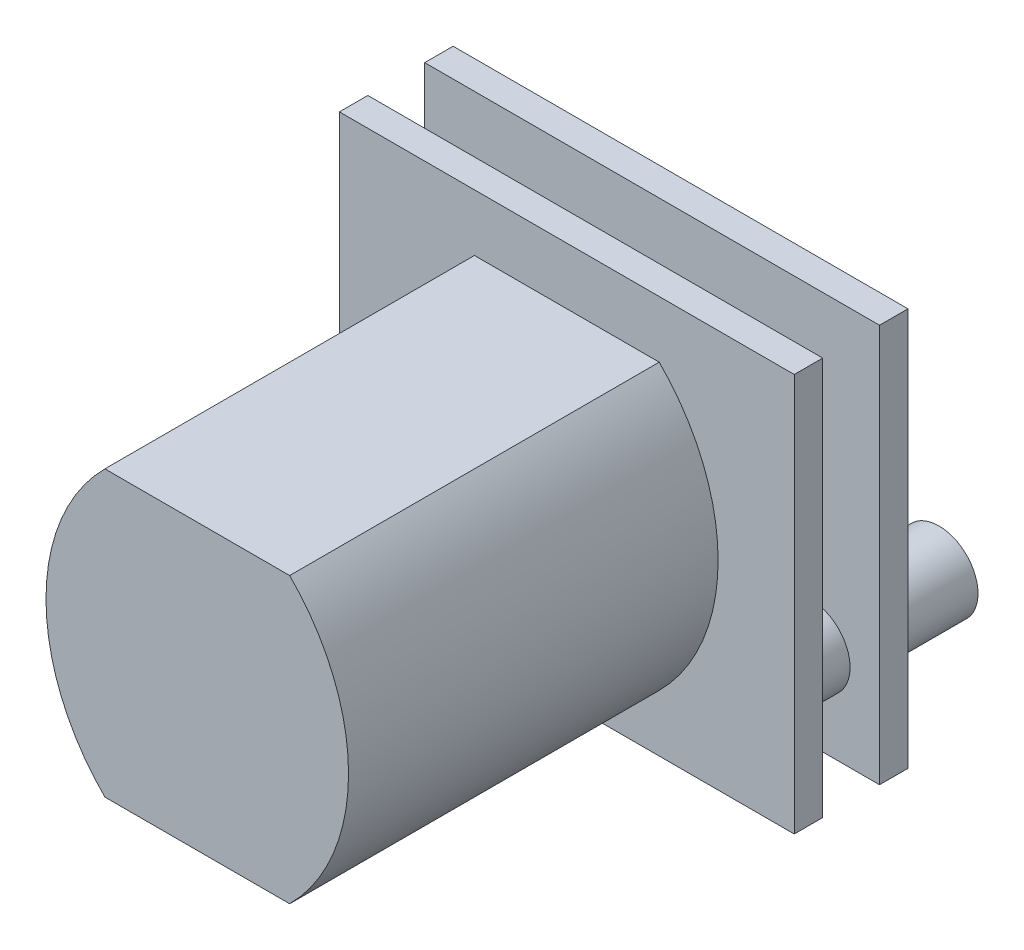
from build123d import *

# Parameters (mm, degrees)
EXTRUDE1_DEPTH  = 13
SKETCH2_W       = 16
SKETCH2_H       = 14
EXTRUDE2_DEPTH  = 1
SKETCH3_R       = 2.248676076
EXTRUDE3_DEPTH  = 1.2
SKETCH4_W       = 0.4
SKETCH4_H       = 0.5
EXTRUDE4_DEPTH  = 1.2
SKETCH5_R       = 1.372998475
EXTRUDE5_DEPTH  = 2
SKETCH6_W       = 16
SKETCH6_H       = 14
EXTRUDE6_DEPTH  = 1
SKETCH7_R       = 1.372998475
EXTRUDE7_DEPTH  = 3.5
SKETCH8_R       = 1.733936405
EXTRUDE8_DEPTH  = 1.2
SKETCH9_W       = 0.301521113
SKETCH9_H       = 0.224907716
EXTRUDE9_DEPTH  = 1.2
SKETCH10_W      = 0.800661527
SKETCH10_H      = 6.121277762
EXTRUDE10_DEPTH = 1.2
SKETCH11_R      = 0.601090718
EXTRUDE11_DEPTH = 1.2
SKETCH12_W      = 0.183794405
SKETCH12_H      = 0.118202218
EXTRUDE12_DEPTH = 1.2
SKETCH13_R      = 2.161420289
EXTRUDE13_DEPTH = 1.2
SKETCH14_W      = 0.467705932
SKETCH14_H      = 0.202573078
EXTRUDE14_DEPTH = 1.2
SKETCH15_R      = 0.577311245
EXTRUDE15_DEPTH = 1.4
SKETCH16_R      = 2.177574352
EXTRUDE16_DEPTH = 0.8
SKETCH17_W      = 0.286885117
SKETCH17_H      = 0.397850676
SKETCH17_W_2    = 0.397850676
SKETCH17_H_2    = 0.286885116
SKETCH17_W_3    = 0.397850677
SKETCH17_W_4    = 0.359139645
SKETCH17_H_3    = 0.201650404
EXTRUDE18_DEPTH = 0.8


with BuildPart() as part:
    # Sketch1 → Extrude1 (new body)
    with BuildSketch(Plane.XY):
        with BuildLine():
            Line((-3.25, 5), (3.25, 5))
            ThreePointArc((3.25, 5), (5.321067812, 0), (3.25, -5))
            Line((3.25, -5), (-3.25, -5))
            ThreePointArc((-3.25, -5), (-5.321067812, 0), (-3.25, 5))
        make_face()
    extrude(amount=EXTRUDE1_DEPTH)

    # Sketch2 → Extrude2 (add)
    with BuildSketch(Plane(origin=(0, 0, 0), x_dir=(-1, 0, 0), z_dir=(0, 0, -1))):
        Rectangle(SKETCH2_W, SKETCH2_H)
    extrude(amount=EXTRUDE2_DEPTH)

    # Sketch3 → Extrude3 (add)
    with BuildSketch(Plane(origin=(0, 0, -1), x_dir=(-1, 0, 0), z_dir=(0, 0, -1))):
        Circle(SKETCH3_R)
    extrude(amount=EXTRUDE3_DEPTH)

    # Sketch4 → Extrude4 (cut)
    with BuildSketch(Plane(origin=(0, 0, -2.2), x_dir=(-1, 0, 0), z_dir=(0, 0, -1))):
        Polygon((-0.459805613, -1.955322187), (-0.622155347, -2.428230808), (-1.000482244, -2.29835102), (-0.838132509, -1.825442399), align=None)
        with Locations((0, -2.248676076)):
            Rectangle(SKETCH4_W, SKETCH4_H)
        Polygon((-1.069784152, -1.700078799), (-1.376890509, -2.094649054), (-1.692546713, -1.848963969), (-1.385440356, -1.454393714), align=None)
        Polygon((-1.56383498, -1.260605494), (-1.982418219, -1.534079573), (-2.201197482, -1.199212982), (-1.782614243, -0.925738903), align=None)
        Polygon((-1.888420022, -0.684526023), (-2.373120155, -0.807268767), (-2.47131435, -0.41950866), (-1.986614217, -0.296765917), align=None)
        Polygon((-2.008365453, -0.034267536), (-2.506657699, 0.007022136), (-2.473625961, 0.405655933), (-1.975333715, 0.364366261), align=None)
        Polygon((-1.910673324, 0.61970437), (-2.368559987, 0.820552082), (-2.207881817, 1.186861413), (-1.749995154, 0.9860137), align=None)
        Polygon((-1.605930093, 1.206521692), (-1.973792048, 1.545162477), (-1.70287942, 1.839452042), (-1.335017464, 1.500811256), align=None)
        Polygon((-1.127159418, 1.662593667), (-1.365133115, 2.102330543), (-1.013343614, 2.2927095), (-0.775369918, 1.852972624), align=None)
        Polygon((-0.52624353, 1.938497821), (-0.608540826, 2.431678473), (-0.213996304, 2.497516309), (-0.131699009, 2.004335657), align=None)
        Polygon((0.131699009, 2.004335657), (0.213996304, 2.497516309), (0.608540826, 2.431678473), (0.52624353, 1.938497821), align=None)
        Polygon((0.775369918, 1.852972624), (1.013343614, 2.2927095), (1.365133115, 2.102330543), (1.127159418, 1.662593667), align=None)
        Polygon((1.335017464, 1.500811256), (1.70287942, 1.839452042), (1.973792048, 1.545162477), (1.605930093, 1.206521692), align=None)
        Polygon((1.749995154, 0.9860137), (2.207881817, 1.186861413), (2.368559987, 0.820552082), (1.910673324, 0.61970437), align=None)
        Polygon((1.975333715, 0.364366261), (2.473625961, 0.405655933), (2.506657699, 0.007022136), (2.008365453, -0.034267536), align=None)
        Polygon((1.986614217, -0.296765917), (2.47131435, -0.41950866), (2.373120155, -0.807268767), (1.888420022, -0.684526023), align=None)
        Polygon((1.782614243, -0.925738903), (2.201197482, -1.199212982), (1.982418219, -1.534079573), (1.56383498, -1.260605494), align=None)
        Polygon((1.385440356, -1.454393714), (1.692546713, -1.848963969), (1.376890509, -2.094649054), (1.069784152, -1.700078799), align=None)
        Polygon((0.838132509, -1.825442399), (1.000482244, -2.29835102), (0.622155347, -2.428230808), (0.459805613, -1.955322187), align=None)
    extrude(amount=-EXTRUDE4_DEPTH, mode=Mode.SUBTRACT)

    # Sketch5 → Extrude5 (add)
    with BuildSketch(Plane(origin=(0, 0, -1), x_dir=(-1, 0, 0), z_dir=(0, 0, -1))):
        with Locations((-5.590617774, -3.94150511)):
            Circle(SKETCH5_R)
    extrude(amount=EXTRUDE5_DEPTH)

    # Sketch6 → Extrude6 (add)
    with BuildSketch(Plane(origin=(0, 0, -3), x_dir=(-1, 0, 0), z_dir=(0, 0, -1))):
        Rectangle(SKETCH6_W, SKETCH6_H)
    extrude(amount=EXTRUDE6_DEPTH)

    # Sketch7 → Extrude7 (add)
    with BuildSketch(Plane(origin=(0, 0, -4), x_dir=(-1, 0, 0), z_dir=(0, 0, -1))):
        with Locations((-5.590617774, -3.94150511)):
            Circle(SKETCH7_R)
    extrude(amount=EXTRUDE7_DEPTH)

    # Sketch8 → Extrude8 (add)
    with BuildSketch(Plane(origin=(0, 0, -4), x_dir=(-1, 0, 0), z_dir=(0, 0, -1))):
        Circle(SKETCH8_R)
    extrude(amount=EXTRUDE8_DEPTH)

    # Sketch9 → Extrude9 (cut)
    with BuildSketch(Plane(origin=(0, 0, -5.2), x_dir=(-1, 0, 0), z_dir=(0, 0, -1))):
        with Locations((1.733936406, 0)):
            Rectangle(SKETCH9_W, SKETCH9_H)
        Polygon((1.840035405, -0.423081807), (1.776671579, -0.638879181), (1.48736419, -0.553930867), (1.550728016, -0.338133493), align=None)
        Polygon((1.646305123, -0.9243419), (1.524710831, -1.113546312), (1.27105513, -0.950531691), (1.392649422, -0.761327279), align=None)
        Polygon((1.319200991, -1.35071731), (1.14922708, -1.498000543), (0.951772743, -1.27012609), (1.121746654, -1.122842858), align=None)
        Polygon((0.885223041, -1.667665637), (0.680639785, -1.761095679), (0.555383388, -1.486822428), (0.759966644, -1.393392385), align=None)
        Polygon((0.379529584, -1.849509612), (0.156911103, -1.881517317), (0.114000175, -1.583065254), (0.336618655, -1.551057549), align=None)
        Polygon((-0.156911103, -1.881517317), (-0.379529584, -1.849509612), (-0.336618655, -1.551057549), (-0.114000175, -1.583065254), align=None)
        Polygon((-0.680639785, -1.761095679), (-0.885223041, -1.667665637), (-0.759966644, -1.393392385), (-0.555383388, -1.486822428), align=None)
        Polygon((-1.14922708, -1.498000543), (-1.319200991, -1.35071731), (-1.121746654, -1.122842858), (-0.951772743, -1.27012609), align=None)
        Polygon((-1.524710831, -1.113546312), (-1.646305123, -0.9243419), (-1.392649422, -0.761327279), (-1.27105513, -0.950531691), align=None)
        Polygon((-1.776671579, -0.638879181), (-1.840035405, -0.423081807), (-1.550728016, -0.338133493), (-1.48736419, -0.553930867), align=None)
        with Locations((-1.733936406, 0)):
            Rectangle(SKETCH9_W, SKETCH9_H)
        Polygon((-1.840035405, 0.423081807), (-1.776671579, 0.638879181), (-1.48736419, 0.553930867), (-1.550728016, 0.338133493), align=None)
        Polygon((-1.646305123, 0.9243419), (-1.524710831, 1.113546312), (-1.27105513, 0.950531691), (-1.392649422, 0.761327279), align=None)
        Polygon((-1.319200991, 1.35071731), (-1.14922708, 1.498000543), (-0.951772743, 1.27012609), (-1.121746654, 1.122842858), align=None)
        Polygon((-0.885223041, 1.667665637), (-0.680639785, 1.761095679), (-0.555383388, 1.486822428), (-0.759966644, 1.393392385), align=None)
        Polygon((-0.379529584, 1.849509612), (-0.156911103, 1.881517317), (-0.114000175, 1.583065254), (-0.336618655, 1.551057549), align=None)
        Polygon((0.156911103, 1.881517317), (0.379529584, 1.849509612), (0.336618655, 1.551057549), (0.114000175, 1.583065254), align=None)
        Polygon((0.680639785, 1.761095679), (0.885223041, 1.667665637), (0.759966644, 1.393392385), (0.555383388, 1.486822428), align=None)
        Polygon((1.14922708, 1.498000543), (1.319200991, 1.35071731), (1.121746654, 1.122842858), (0.951772743, 1.27012609), align=None)
        Polygon((1.524710831, 1.113546312), (1.646305123, 0.9243419), (1.392649422, 0.761327279), (1.27105513, 0.950531691), align=None)
        Polygon((1.776671579, 0.638879181), (1.840035405, 0.423081807), (1.550728016, 0.338133493), (1.48736419, 0.553930867), align=None)
    extrude(amount=-EXTRUDE9_DEPTH, mode=Mode.SUBTRACT)

    # Sketch10 → Extrude10 (cut)
    with BuildSketch(Plane.XZ.offset(5)):
        with Locations((1.473917579, 5.887601999)):
            Rectangle(SKETCH10_W, SKETCH10_H)
        with Locations((-1.526082421, 5.887601999)):
            Rectangle(SKETCH10_W, SKETCH10_H)
    extrude(amount=-EXTRUDE10_DEPTH, mode=Mode.SUBTRACT)

    # Sketch11 → Extrude11 (add)
    with BuildSketch(Plane(origin=(0, 0, -5.2), x_dir=(-1, 0, 0), z_dir=(0, 0, -1))):
        Circle(SKETCH11_R)
    extrude(amount=EXTRUDE11_DEPTH)

    # Sketch12 → Extrude12 (cut)
    with BuildSketch(Plane(origin=(0, 0, -6.4), x_dir=(-1, 0, 0), z_dir=(0, 0, -1))):
        with Locations((-0.601090719, 0)):
            Rectangle(SKETCH12_W, SKETCH12_H)
        Polygon((-0.498699159, 0.118617563), (-0.458271619, 0.229691315), (-0.630981866, 0.292552704), (-0.671409406, 0.181478952), align=None)
        Polygon((-0.428054323, 0.282029207), (-0.352075403, 0.372577359), (-0.492870086, 0.490718125), (-0.568849007, 0.400169974), align=None)
        Polygon((-0.305779819, 0.411423965), (-0.203413696, 0.470525074), (-0.295310899, 0.629695699), (-0.397677022, 0.57059459), align=None)
        Polygon((-0.146623756, 0.491194922), (-0.030217296, 0.511720522), (-0.06213286, 0.692722678), (-0.17853932, 0.672197078), align=None)
        Polygon((0.030217296, 0.511720522), (0.146623756, 0.491194922), (0.17853932, 0.672197078), (0.06213286, 0.692722678), align=None)
        Polygon((0.203413696, 0.470525074), (0.305779819, 0.411423965), (0.397677022, 0.57059459), (0.295310899, 0.629695699), align=None)
        Polygon((0.352075403, 0.372577359), (0.428054323, 0.282029207), (0.568849007, 0.400169974), (0.492870086, 0.490718125), align=None)
        Polygon((0.458271619, 0.229691315), (0.498699159, 0.118617563), (0.671409406, 0.181478952), (0.630981866, 0.292552704), align=None)
        with Locations((0.601090719, 0)):
            Rectangle(SKETCH12_W, SKETCH12_H)
        Polygon((0.498699159, -0.118617563), (0.458271619, -0.229691315), (0.630981866, -0.292552704), (0.671409406, -0.181478952), align=None)
        Polygon((0.428054323, -0.282029207), (0.352075403, -0.372577359), (0.492870086, -0.490718125), (0.568849007, -0.400169974), align=None)
        Polygon((0.305779819, -0.411423965), (0.203413696, -0.470525074), (0.295310899, -0.629695699), (0.397677022, -0.57059459), align=None)
        Polygon((0.146623756, -0.491194922), (0.030217296, -0.511720522), (0.06213286, -0.692722678), (0.17853932, -0.672197078), align=None)
        Polygon((-0.030217296, -0.511720522), (-0.146623756, -0.491194922), (-0.17853932, -0.672197078), (-0.06213286, -0.692722678), align=None)
        Polygon((-0.203413696, -0.470525074), (-0.305779819, -0.411423965), (-0.397677022, -0.57059459), (-0.295310899, -0.629695699), align=None)
        Polygon((-0.352075403, -0.372577359), (-0.428054323, -0.282029207), (-0.568849007, -0.400169974), (-0.492870086, -0.490718125), align=None)
        Polygon((-0.458271619, -0.229691315), (-0.498699159, -0.118617563), (-0.671409406, -0.181478952), (-0.630981866, -0.292552704), align=None)
    extrude(amount=-EXTRUDE12_DEPTH, mode=Mode.SUBTRACT)

    # Sketch13 → Extrude13 (add)
    with BuildSketch(Plane(origin=(0, 0, -6.4), x_dir=(-1, 0, 0), z_dir=(0, 0, -1))):
        Circle(SKETCH13_R)
    extrude(amount=EXTRUDE13_DEPTH)

    # Sketch14 → Extrude14 (cut)
    with BuildSketch(Plane(origin=(0, 0, -7.6), x_dir=(-1, 0, 0), z_dir=(0, 0, -1))):
        with Locations((-2.161420289, 0)):
            Rectangle(SKETCH14_W, SKETCH14_H)
        Polygon((-2.349910423, 0.474883074), (-2.301431513, 0.671569746), (-1.847316265, 0.55964039), (-1.895795176, 0.362953719), align=None)
        Polygon((-2.167979339, 1.023454209), (-2.073838936, 1.202823761), (-1.6597059, 0.985469977), (-1.753846303, 0.806100425), align=None)
        Polygon((-1.860053175, 1.512545906), (-1.725722378, 1.664174031), (-1.375639461, 1.35402763), (-1.509970258, 1.202399505), align=None)
        Polygon((-1.444027482, 1.913733932), (-1.277313108, 2.028808556), (-1.011625856, 1.64389412), (-1.178340231, 1.528819496), align=None)
        Polygon((-0.944080161, 2.203702698), (-0.754671043, 2.275536101), (-0.588820234, 1.838223458), (-0.778229352, 1.766390055), align=None)
        Polygon((-0.389266332, 2.365600273), (-0.188170241, 2.39001776), (-0.13179452, 1.925721931), (-0.332890612, 1.901304444), align=None)
        Polygon((0.188170241, 2.39001776), (0.389266332, 2.365600273), (0.332890612, 1.901304444), (0.13179452, 1.925721931), align=None)
        Polygon((0.754671043, 2.275536101), (0.944080161, 2.203702698), (0.778229352, 1.766390055), (0.588820234, 1.838223458), align=None)
        Polygon((1.277313108, 2.028808556), (1.444027482, 1.913733932), (1.178340231, 1.528819496), (1.011625856, 1.64389412), align=None)
        Polygon((1.725722378, 1.664174031), (1.860053175, 1.512545906), (1.509970258, 1.202399505), (1.375639461, 1.35402763), align=None)
        Polygon((2.073838936, 1.202823761), (2.167979339, 1.023454209), (1.753846303, 0.806100425), (1.6597059, 0.985469977), align=None)
        Polygon((2.301431513, 0.671569746), (2.349910423, 0.474883074), (1.895795176, 0.362953719), (1.847316265, 0.55964039), align=None)
        with Locations((2.161420289, 0)):
            Rectangle(SKETCH14_W, SKETCH14_H)
        Polygon((2.349910423, -0.474883074), (2.301431513, -0.671569746), (1.847316265, -0.55964039), (1.895795176, -0.362953719), align=None)
        Polygon((2.167979339, -1.023454209), (2.073838936, -1.202823761), (1.6597059, -0.985469977), (1.753846303, -0.806100425), align=None)
        Polygon((1.860053175, -1.512545906), (1.725722378, -1.664174031), (1.375639461, -1.35402763), (1.509970258, -1.202399505), align=None)
        Polygon((1.444027482, -1.913733932), (1.277313108, -2.028808556), (1.011625856, -1.64389412), (1.178340231, -1.528819496), align=None)
        Polygon((0.944080161, -2.203702698), (0.754671043, -2.275536101), (0.588820234, -1.838223458), (0.778229352, -1.766390055), align=None)
        Polygon((0.389266332, -2.365600273), (0.188170241, -2.39001776), (0.13179452, -1.925721931), (0.332890612, -1.901304444), align=None)
        Polygon((-0.188170241, -2.39001776), (-0.389266332, -2.365600273), (-0.332890612, -1.901304444), (-0.13179452, -1.925721931), align=None)
        Polygon((-0.754671043, -2.275536101), (-0.944080161, -2.203702698), (-0.778229352, -1.766390055), (-0.588820234, -1.838223458), align=None)
        Polygon((-1.277313108, -2.028808556), (-1.444027482, -1.913733932), (-1.178340231, -1.528819496), (-1.011625856, -1.64389412), align=None)
        Polygon((-1.725722378, -1.664174031), (-1.860053175, -1.512545906), (-1.509970258, -1.202399505), (-1.375639461, -1.35402763), align=None)
        Polygon((-2.073838936, -1.202823761), (-2.167979339, -1.023454209), (-1.753846303, -0.806100425), (-1.6597059, -0.985469977), align=None)
        Polygon((-2.301431513, -0.671569746), (-2.349910423, -0.474883074), (-1.895795176, -0.362953719), (-1.847316265, -0.55964039), align=None)
    extrude(amount=-EXTRUDE14_DEPTH, mode=Mode.SUBTRACT)

    # Sketch15 → Extrude15 (add)
    with BuildSketch(Plane(origin=(0, 0, -4), x_dir=(-1, 0, 0), z_dir=(0, 0, -1))):
        with Locations((-2.942375977, 0)):
            Circle(SKETCH15_R)
    extrude(amount=EXTRUDE15_DEPTH)

    # Sketch16 → Extrude16 (add)
    with BuildSketch(Plane(origin=(0, 0, -5.4), x_dir=(-1, 0, 0), z_dir=(0, 0, -1))):
        with Locations((-2.942375977, 0)):
            Circle(SKETCH16_R)
    extrude(amount=EXTRUDE16_DEPTH)

    # Sketch17 → Extrude18 (cut)
    with BuildSketch(Plane(origin=(0, 0, -6.2), x_dir=(-1, 0, 0), z_dir=(0, 0, -1))):
        with Locations((-2.942375977, 2.177574352)):
            Rectangle(SKETCH17_W, SKETCH17_H)
        Polygon((-2.467361785, 1.926133226), (-2.344419165, 2.304511704), (-2.071575206, 2.215859328), (-2.194517826, 1.83748085), align=None)
        Polygon((-1.895402735, 1.685074098), (-1.661551974, 2.006942057), (-1.429457039, 1.838315216), (-1.6633078, 1.516447258), align=None)
        Polygon((-1.425928719, 1.279068177), (-1.104060761, 1.512918937), (-0.93543392, 1.280824003), (-1.257301879, 1.046973242), align=None)
        Polygon((-1.104895127, 0.747858151), (-0.726516649, 0.870800771), (-0.637864272, 0.597956812), (-1.016242751, 0.475014191), align=None)
        with Locations((-0.764801625, 0)):
            Rectangle(SKETCH17_W_2, SKETCH17_H_2)
        Polygon((-1.016242751, -0.475014191), (-0.637864272, -0.597956812), (-0.726516649, -0.870800771), (-1.104895127, -0.747858151), align=None)
        Polygon((-1.257301879, -1.046973242), (-0.93543392, -1.280824003), (-1.104060761, -1.512918937), (-1.425928719, -1.279068177), align=None)
        Polygon((-1.6633078, -1.516447258), (-1.429457039, -1.838315216), (-1.661551974, -2.006942057), (-1.895402735, -1.685074098), align=None)
        Polygon((-2.194517826, -1.83748085), (-2.071575206, -2.215859328), (-2.344419165, -2.304511704), (-2.467361785, -1.926133226), align=None)
        with Locations((-2.942375977, -2.177574352)):
            Rectangle(SKETCH17_W, SKETCH17_H)
        Polygon((-3.417390168, -1.926133226), (-3.540332788, -2.304511704), (-3.813176748, -2.215859328), (-3.690234128, -1.83748085), align=None)
        Polygon((-3.989349219, -1.685074098), (-4.223199979, -2.006942057), (-4.455294914, -1.838315216), (-4.221444154, -1.516447258), align=None)
        Polygon((-4.458823234, -1.279068177), (-4.780691193, -1.512918937), (-4.949318034, -1.280824003), (-4.627450075, -1.046973242), align=None)
        Polygon((-4.779856826, -0.747858151), (-5.158235305, -0.870800771), (-5.246887681, -0.597956812), (-4.868509203, -0.475014191), align=None)
        with Locations((-5.119950328, 0)):
            Rectangle(SKETCH17_W_3, SKETCH17_H_2)
        with Locations((-5.119950328, 0)):
            Rectangle(SKETCH17_W_4, SKETCH17_H_3, mode=Mode.SUBTRACT)
        Polygon((-4.868509203, 0.475014191), (-5.246887681, 0.597956812), (-5.158235305, 0.870800771), (-4.779856826, 0.747858151), align=None)
        Polygon((-4.627450075, 1.046973242), (-4.949318034, 1.280824003), (-4.780691193, 1.512918937), (-4.458823234, 1.279068177), align=None)
        Polygon((-4.221444154, 1.516447258), (-4.455294914, 1.838315216), (-4.223199979, 2.006942057), (-3.989349219, 1.685074098), align=None)
        Polygon((-3.690234128, 1.83748085), (-3.813176748, 2.215859328), (-3.540332788, 2.304511704), (-3.417390168, 1.926133226), align=None)
    extrude(amount=-EXTRUDE18_DEPTH, mode=Mode.SUBTRACT)


solid = part.part
